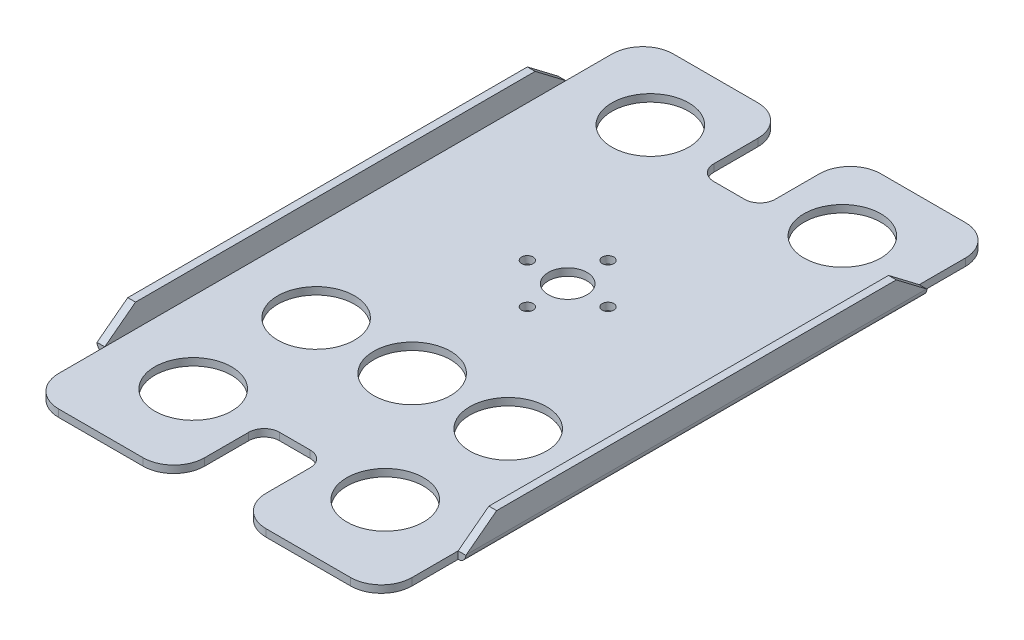
from build123d import *

# Parameters (mm, degrees)
SKETCH1_R               = 7.9375
SKETCH1_R_2             = 4.0005
SKETCH1_R_3             = 1.1938
EXTRUDE1_DEPTH          = 1.524
EXTRUDE2_DEPTH          = 6.35
CUT_EXTRUDE1_DEPTH      = 39.1
CUT_EXTRUDE1_DEPTH_BACK = 39.1
FILLET1_R               = 1.5875


with BuildPart() as part:
    # Sketch1 → Extrude1 (new body)
    with BuildSketch(Plane(origin=(0, 0, 0), x_dir=(1, 0, 0), z_dir=(0, 1, 0))):
        with BuildLine():
            Line((36.4998, -62.3062), (36.4998, 36.1188))
            Line((36.4998, 36.1188), (36.4998, 39.2938))
            Line((36.4998, 39.2938), (36.4998, 45.6438))
            ThreePointArc((36.4998, 45.6438), (34.639928061, 50.133928061), (30.1498, 51.9938))
            Line((30.1498, 51.9938), (23.7998, 51.9938))
            Line((23.7998, 51.9938), (12.7, 51.9938))
            ThreePointArc((12.7, 51.9938), (8.209871939, 50.133928061), (6.35, 45.6438))
            Line((6.35, 45.6438), (6.35, 36.5252))
            ThreePointArc((6.35, 36.5252), (5.42006403, 34.28013597), (3.175, 33.3502))
            Line((3.175, 33.3502), (-3.175, 33.3502))
            ThreePointArc((-3.175, 33.3502), (-5.42006403, 34.28013597), (-6.35, 36.5252))
            Line((-6.35, 36.5252), (-6.35, 45.6438))
            ThreePointArc((-6.35, 45.6438), (-8.209871939, 50.133928061), (-12.7, 51.9938))
            Line((-12.7, 51.9938), (-23.7998, 51.9938))
            Line((-23.7998, 51.9938), (-30.1498, 51.9938))
            ThreePointArc((-30.1498, 51.9938), (-34.639928061, 50.133928061), (-36.4998, 45.6438))
            Line((-36.4998, 45.6438), (-36.4998, 39.2938))
            Line((-36.4998, 39.2938), (-36.4998, 36.1188))
            Line((-36.4998, 36.1188), (-36.4998, -62.3062))
            Line((-36.4998, -62.3062), (-36.4998, -68.6562))
            ThreePointArc((-36.4998, -68.6562), (-34.639928061, -73.146328061), (-30.1498, -75.0062))
            Line((-30.1498, -75.0062), (-23.7998, -75.0062))
            Line((-23.7998, -75.0062), (-12.7, -75.0062))
            ThreePointArc((-12.7, -75.0062), (-8.209871939, -73.146328061), (-6.35, -68.6562))
            Line((-6.35, -68.6562), (-6.35, -59.5376))
            ThreePointArc((-6.35, -59.5376), (-5.42006403, -57.29253597), (-3.175, -56.3626))
            Line((-3.175, -56.3626), (3.175, -56.3626))
            ThreePointArc((3.175, -56.3626), (5.42006403, -57.29253597), (6.35, -59.5376))
            Line((6.35, -59.5376), (6.35, -68.6562))
            ThreePointArc((6.35, -68.6562), (8.209871939, -73.146328061), (12.7, -75.0062))
            Line((12.7, -75.0062), (23.7998, -75.0062))
            Line((23.7998, -75.0062), (30.1498, -75.0062))
            ThreePointArc((30.1498, -75.0062), (34.639928061, -73.146328061), (36.4998, -68.6562))
            Line((36.4998, -68.6562), (36.4998, -62.3062))
        make_face()
        with Locations(Location((19.8374, -57.531, 0), (0, 0, 270))):  # turned: the seam where the file's is
            Circle(SKETCH1_R, mode=Mode.SUBTRACT)
        with Locations(Location((19.8374, -32.131, 0), (0, 0, 270))):  # turned: the seam where the file's is
            Circle(SKETCH1_R, mode=Mode.SUBTRACT)
        with Locations(Location((0, 0, 0), (0, 0, 270))):  # turned: the seam where the file's is
            Circle(SKETCH1_R_2, mode=Mode.SUBTRACT)
        with Locations(Location((8.3312, 0, 0), (0, 0, 270))):  # turned: the seam where the file's is
            Circle(SKETCH1_R_3, mode=Mode.SUBTRACT)
        with Locations(Location((0, -8.3312, 0), (0, 0, 270))):  # turned: the seam where the file's is
            Circle(SKETCH1_R_3, mode=Mode.SUBTRACT)
        with Locations(Location((0, 8.3312, 0), (0, 0, 270))):  # turned: the seam where the file's is
            Circle(SKETCH1_R_3, mode=Mode.SUBTRACT)
        with Locations(Location((-8.3312, 0, 0), (0, 0, 270))):  # turned: the seam where the file's is
            Circle(SKETCH1_R_3, mode=Mode.SUBTRACT)
        with Locations(Location((19.8374, 36.9062, 0), (0, 0, 270))):  # turned: the seam where the file's is
            Circle(SKETCH1_R, mode=Mode.SUBTRACT)
        with Locations(Location((0, -32.131, 0), (0, 0, 270))):  # turned: the seam where the file's is
            Circle(SKETCH1_R, mode=Mode.SUBTRACT)
        with Locations(Location((-19.8374, 36.9062, 0), (0, 0, 270))):  # turned: the seam where the file's is
            Circle(SKETCH1_R, mode=Mode.SUBTRACT)
        with Locations(Location((-19.8374, -32.131, 0), (0, 0, 270))):  # turned: the seam where the file's is
            Circle(SKETCH1_R, mode=Mode.SUBTRACT)
        with Locations(Location((-19.8374, -57.531, 0), (0, 0, 270))):  # turned: the seam where the file's is
            Circle(SKETCH1_R, mode=Mode.SUBTRACT)
    extrude(amount=EXTRUDE1_DEPTH)

    # Sketch1_3 → Extrude2 (add)
    with BuildSketch(Plane(origin=(0, 0, 0), x_dir=(1, 0, 0), z_dir=(0, 1, 0))):
        Polygon((36.4998, 36.1188), (36.4998, -59.1312), (38.1, -59.1312), (38.1, 29.7688), (38.1, 36.1188), align=None)
        Polygon((-38.1, -59.1312), (-36.4998, -59.1312), (-36.4998, 36.1188), (-38.1, 36.1188), (-38.1, 29.7688), align=None)
    extrude(amount=EXTRUDE2_DEPTH)

    # Sketch2 → Cut-Extrude1 (cut, two sides)
    with BuildSketch(Plane(origin=(0, 0, 0), x_dir=(0, 0, -1), z_dir=(1, 0, 0))) as cut_extrude1_sk:
        Polygon((-59.1312, 6.35), (-59.1312, 1.524), (-52.7812, 6.35), align=None)
        Polygon((36.1188, 6.35), (29.7688, 6.35), (36.1188, 1.524), align=None)
    extrude(amount=CUT_EXTRUDE1_DEPTH, mode=Mode.SUBTRACT)
    extrude(cut_extrude1_sk.sketch, amount=-CUT_EXTRUDE1_DEPTH_BACK, mode=Mode.SUBTRACT)

    # Fillet1
    fillet1_edges = [part.edges().sort_by_distance(p)[0] for p in [
        (38.1, 0, 11.5062),
        (-38.1, 0, 11.5062),
    ]]
    fillet(fillet1_edges, radius=FILLET1_R)


solid = part.part
